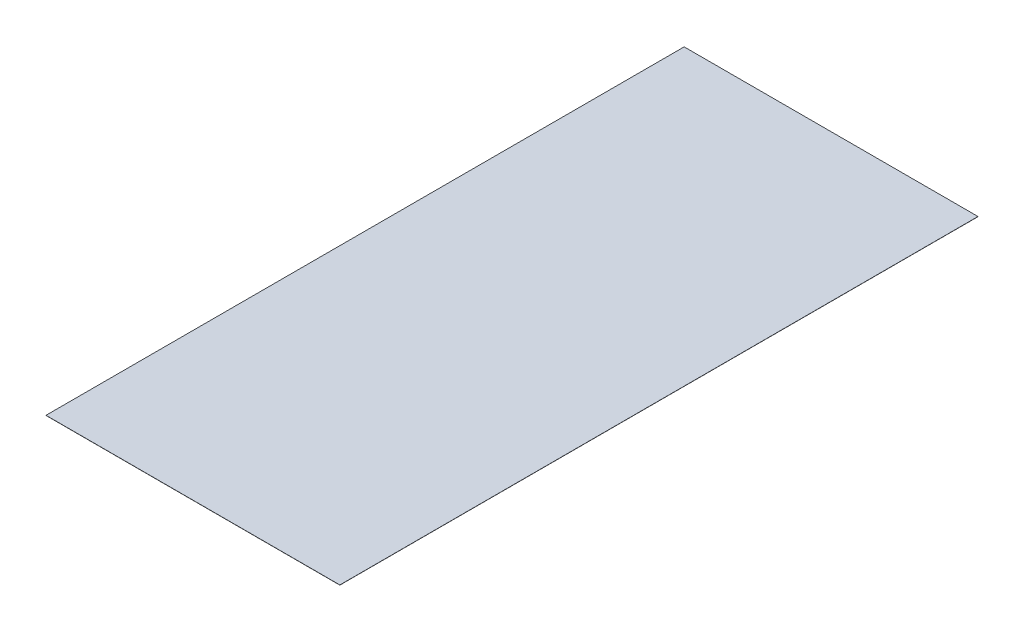
from build123d import *

# Parameters (mm, degrees)
SKETCH2_W           = 536.448
SKETCH2_H           = 1165.076918
BOSS_EXTRUDE2_DEPTH = 0.3175


with BuildPart() as part:
    # Sketch2 → Boss-Extrude2 (new body)
    with BuildSketch(Plane(origin=(0, 0, 0), x_dir=(1, 0, 0), z_dir=(0, 1, 0))):
        with Locations((268.224, 582.538459)):
            Rectangle(SKETCH2_W, SKETCH2_H)
    extrude(amount=BOSS_EXTRUDE2_DEPTH)


solid = part.part
